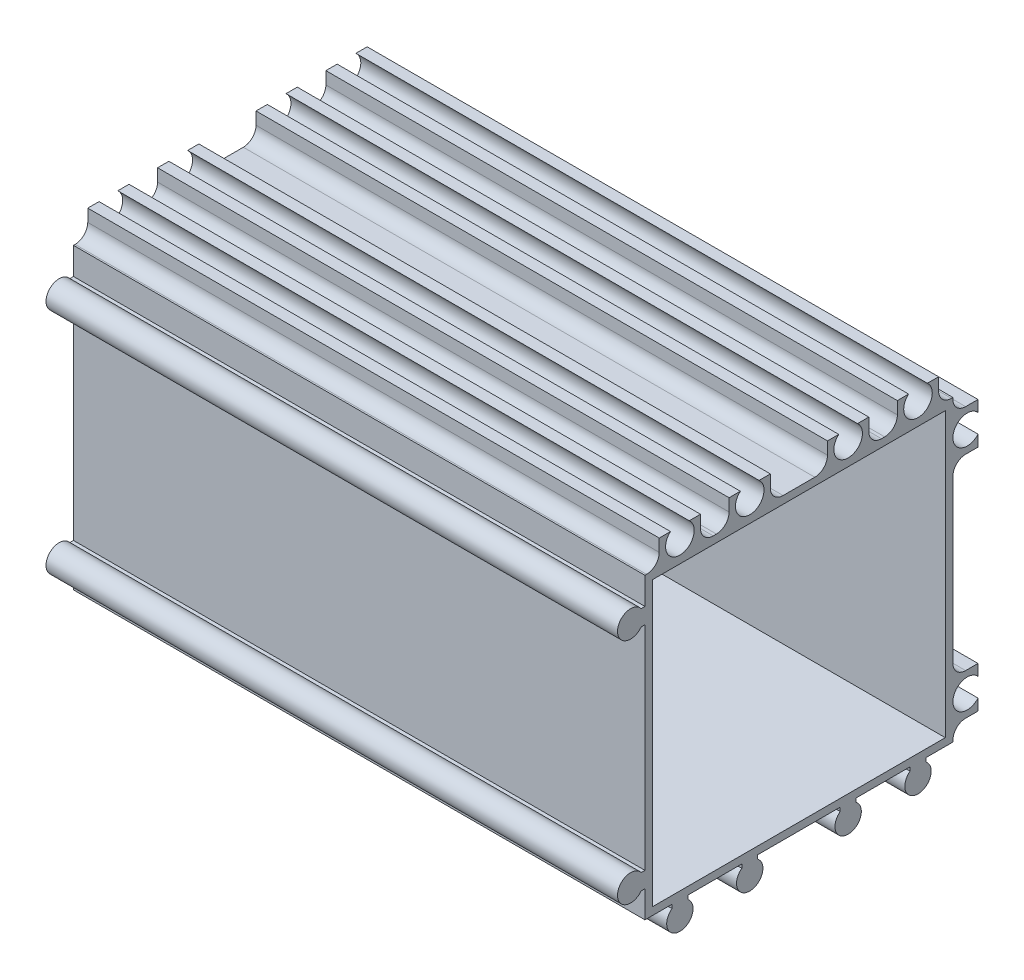
from build123d import *

# Parameters (mm, degrees)
EXTRUDE_1_DEPTH             = 90
SKETCH_2_W                  = 90
SKETCH_2_H                  = 42.75
EXTRUDE_2_DEPTH             = 8.2
SKETCH_3_W                  = 90
SKETCH_3_H                  = 52.45
EXTRUDE_3_DEPTH             = 8.2
SKETCH_4_W                  = 3.95
SKETCH_4_H                  = 2.25
CUT_EXTRUDE_1_DEPTH         = 91
SKETCH_5_W                  = 3.95
SKETCH_5_H                  = 29.5
CUT_EXTRUDE_2_DEPTH         = 91
SKETCH_6_W                  = 3.95
SKETCH_6_H                  = 6.2
CUT_EXTRUDE_3_DEPTH         = 91
SKETCH_7_W                  = 2.25
SKETCH_7_H                  = 3.95
CUT_EXTRUDE_4_DEPTH         = 91
SKETCH_8_W                  = 4.5
SKETCH_8_H                  = 3.95
CUT_EXTRUDE_5_DEPTH         = 91
SKETCH_9_W                  = 9
SKETCH_9_H                  = 3.95
CUT_EXTRUDE_6_DEPTH         = 91
SKETCH_10_W                 = 4.5
SKETCH_10_H                 = 3.95
CUT_EXTRUDE_7_DEPTH         = 91
SKETCH_11_W                 = 2.25
SKETCH_11_H                 = 3.95
CUT_EXTRUDE_8_DEPTH         = 91
SKETCH_12_W                 = 46.1
SKETCH_12_H                 = 44.6
CUT_EXTRUDE_9_DEPTH         = 86.2
HOLE_WIZARD_2_5_2_5_1_D     = 2.5
HOLE_WIZARD_2_5_2_5_1_DEPTH = 90
HOLE_WIZARD_4_5_4_5_1_D     = 4.5
HOLE_WIZARD_4_5_4_5_1_DEPTH = 90
SKETCH_19_R                 = 1.67252853
SKETCH_19_R_2               = 1.459159852
SKETCH_19_R_3               = 1.459908976
SKETCH_19_R_4               = 1.592821911
SKETCH_19_R_5               = 1.532216665
SKETCH_19_R_6               = 1.596138091
EXTRUDE_4_DEPTH             = 90
FILLET_1_R                  = 2
FILLET_2_R                  = 2
FILLET_3_R                  = 2
FILLET_4_R                  = 2
FILLET_5_R                  = 2
FILLET_6_R                  = 2
FILLET_7_R                  = 2
FILLET_8_R                  = 2
FILLET_9_R                  = 2
FILLET_10_R                 = 2
FILLET_11_R                 = 2
FILLET_12_R                 = 2


with BuildPart() as part:
    # Эскиз1 → Бобышка-Вытянуть1 (new body)
    with BuildSketch(Plane(origin=(90, 0, 0), x_dir=(0, 0, -1), z_dir=(1, 0, 0))):
        with BuildLine():
            Line((6.75, 160.906238208), (6.75, 204.25))
            Line((6.75, 204.25), (-38.093761792, 204.25))
            ThreePointArc((-38.093761792, 204.25), (-41.825, 203), (-38.093761792, 201.75))
            Line((-38.093761792, 201.75), (-37.5, 201.75))
            Line((-37.5, 201.75), (-37.5, 168.25))
            Line((-37.5, 168.25), (-38.093761792, 168.25))
            ThreePointArc((-38.093761792, 168.25), (-41.825, 167), (-38.093761792, 165.75))
            Line((-38.093761792, 165.75), (-37.5, 165.75))
            Line((-37.5, 165.75), (-37.5, 161.5))
            Line((-37.5, 161.5), (-33.25, 161.5))
            Line((-33.25, 161.5), (-33.25, 160.906238208))
            ThreePointArc((-33.25, 160.906238208), (-32, 157.175), (-30.75, 160.906238208))
            Line((-30.75, 160.906238208), (-30.75, 161.5))
            Line((-30.75, 161.5), (-22.25, 161.5))
            Line((-22.25, 161.5), (-22.25, 160.906238208))
            ThreePointArc((-22.25, 160.906238208), (-21, 157.175), (-19.75, 160.906238208))
            Line((-19.75, 160.906238208), (-19.75, 161.5))
            Line((-19.75, 161.5), (-6.75, 161.5))
            Line((-6.75, 161.5), (-6.75, 160.906238208))
            ThreePointArc((-6.75, 160.906238208), (-5.5, 157.175), (-4.25, 160.906238208))
            Line((-4.25, 160.906238208), (-4.25, 161.5))
            Line((-4.25, 161.5), (4.25, 161.5))
            Line((4.25, 161.5), (4.25, 160.906238208))
            ThreePointArc((4.25, 160.906238208), (5.5, 157.175), (6.75, 160.906238208))
        make_face()
    extrude(amount=-EXTRUDE_1_DEPTH)

    # Эскиз2 → Бобышка-Вытянуть2 (add)
    with BuildSketch(Plane(origin=(0, 0, -6.75), x_dir=(-1, 0, 0), z_dir=(0, 0, -1))):
        with Locations((-45, 182.875)):
            Rectangle(SKETCH_2_W, SKETCH_2_H)
    extrude(amount=EXTRUDE_2_DEPTH)

    # Эскиз3 → Бобышка-Вытянуть3 (add)
    with BuildSketch(Plane(origin=(0, 204.25, 0), x_dir=(-1, 0, 0), z_dir=(0, 1, 0))):
        with Locations((-45, 11.275)):
            Rectangle(SKETCH_3_W, SKETCH_3_H)
    extrude(amount=EXTRUDE_3_DEPTH)

    # Эскиз4 → Вырез-Вытянуть1 (cut, through all)
    with BuildSketch(Plane.ZY):
        with Locations((-12.975, 162.625)):
            Rectangle(SKETCH_4_W, SKETCH_4_H)
    extrude(amount=-CUT_EXTRUDE_1_DEPTH, mode=Mode.SUBTRACT)

    # Эскиз5 → Вырез-Вытянуть2 (cut, through all)
    with BuildSketch(Plane.ZY):
        with Locations((-12.975, 185)):
            Rectangle(SKETCH_5_W, SKETCH_5_H)
    extrude(amount=-CUT_EXTRUDE_2_DEPTH, mode=Mode.SUBTRACT)

    # Эскиз6 → Вырез-Вытянуть3 (cut, through all)
    with BuildSketch(Plane.ZY):
        with Locations((-12.975, 209.35)):
            Rectangle(SKETCH_6_W, SKETCH_6_H)
    extrude(amount=-CUT_EXTRUDE_3_DEPTH, mode=Mode.SUBTRACT)

    # Эскиз7 → Вырез-Вытянуть4 (cut, through all)
    with BuildSketch(Plane.ZY):
        with Locations((-9.875, 210.475)):
            Rectangle(SKETCH_7_W, SKETCH_7_H)
    extrude(amount=-CUT_EXTRUDE_4_DEPTH, mode=Mode.SUBTRACT)

    # Эскиз8 → Вырез-Вытянуть5 (cut, through all)
    with BuildSketch(Plane.ZY):
        with Locations((0, 210.475)):
            Rectangle(SKETCH_8_W, SKETCH_8_H)
    extrude(amount=-CUT_EXTRUDE_5_DEPTH, mode=Mode.SUBTRACT)

    # Эскиз9 → Вырез-Вытянуть6 (cut, through all)
    with BuildSketch(Plane.ZY):
        with Locations((13.25, 210.475)):
            Rectangle(SKETCH_9_W, SKETCH_9_H)
    extrude(amount=-CUT_EXTRUDE_6_DEPTH, mode=Mode.SUBTRACT)

    # Эскиз10 → Вырез-Вытянуть7 (cut, through all)
    with BuildSketch(Plane.ZY):
        with Locations((26.5, 210.475)):
            Rectangle(SKETCH_10_W, SKETCH_10_H)
    extrude(amount=-CUT_EXTRUDE_7_DEPTH, mode=Mode.SUBTRACT)

    # Эскиз11 → Вырез-Вытянуть8 (cut, through all)
    with BuildSketch(Plane.ZY):
        with Locations((36.375, 210.475)):
            Rectangle(SKETCH_11_W, SKETCH_11_H)
    extrude(amount=-CUT_EXTRUDE_8_DEPTH, mode=Mode.SUBTRACT)

    # Эскиз12 → Вырез-Вытянуть9 (cut)
    with BuildSketch(Plane(origin=(90, 0, 0), x_dir=(0, 0, -1), z_dir=(1, 0, 0))):
        with Locations((-13.25, 185)):
            Rectangle(SKETCH_12_W, SKETCH_12_H)
    extrude(amount=-CUT_EXTRUDE_9_DEPTH, mode=Mode.SUBTRACT)

    # Диаметр отверстия Ø2.5 (2.5)1
    with Locations(Plane(origin=(90, 0, 0), x_dir=(0, 0, -1), z_dir=(1, 0, 0))):
        with Locations((5.5, 159.25), (-21, 159.25), (-5.5, 159.25), (-32, 159.25), (-39.75, 167), (-39.75, 203)):
            Hole(HOLE_WIZARD_2_5_2_5_1_D / 2, depth=HOLE_WIZARD_2_5_2_5_1_DEPTH)

    # Диаметр отверстия Ø4.5 (4.5)1
    with Locations(Plane.ZY):
        with Locations((-13.25, 167), (-13.25, 203), (-5.5, 210.75), (5.5, 210.75), (21, 210.75), (32, 210.75)):
            Hole(HOLE_WIZARD_4_5_4_5_1_D / 2, depth=HOLE_WIZARD_4_5_4_5_1_DEPTH)

    # Эскиз19 → Бобышка-Вытянуть4 (add)
    with BuildSketch(Plane(origin=(90, 0, 0), x_dir=(0, 0, -1), z_dir=(1, 0, 0))):
        with Locations((-39.75, 203)):
            Circle(SKETCH_19_R)
        with Locations((-39.75, 167)):
            Circle(SKETCH_19_R_2)
        with Locations((-32, 159.25)):
            Circle(SKETCH_19_R_3)
        with Locations((-21, 159.25)):
            Circle(SKETCH_19_R_4)
        with Locations((-5.5, 159.25)):
            Circle(SKETCH_19_R_5)
        with Locations((5.5, 159.25)):
            Circle(SKETCH_19_R_6)
    extrude(amount=-EXTRUDE_4_DEPTH)

    # Скругление1
    fillet_1_edges = [part.edges().sort_by_distance(p)[0] for p in [
        (45, 208.5, -8.75),
    ]]
    fillet(fillet_1_edges, radius=FILLET_1_R)

    # Скругление2
    fillet_2_edges = [part.edges().sort_by_distance(p)[0] for p in [
        (45, 163.75, -11),
    ]]
    fillet(fillet_2_edges, radius=FILLET_2_R)

    # Скругление3
    fillet_3_edges = [part.edges().sort_by_distance(p)[0] for p in [
        (45, 170.25, -11),
    ]]
    fillet(fillet_3_edges, radius=FILLET_3_R)

    # Скругление4
    fillet_4_edges = [part.edges().sort_by_distance(p)[0] for p in [
        (45, 199.75, -11),
    ]]
    fillet(fillet_4_edges, radius=FILLET_4_R)

    # Скругление5
    fillet_5_edges = [part.edges().sort_by_distance(p)[0] for p in [
        (45, 206.25, -11),
    ]]
    fillet(fillet_5_edges, radius=FILLET_5_R)

    # Скругление6
    fillet_6_edges = [part.edges().sort_by_distance(p)[0] for p in [
        (45, 208.5, -2.25),
    ]]
    fillet(fillet_6_edges, radius=FILLET_6_R)

    # Скругление7
    fillet_7_edges = [part.edges().sort_by_distance(p)[0] for p in [
        (45, 208.5, 2.25),
    ]]
    fillet(fillet_7_edges, radius=FILLET_7_R)

    # Скругление8
    fillet_8_edges = [part.edges().sort_by_distance(p)[0] for p in [
        (45, 208.5, 8.75),
    ]]
    fillet(fillet_8_edges, radius=FILLET_8_R)

    # Скругление9
    fillet_9_edges = [part.edges().sort_by_distance(p)[0] for p in [
        (45, 208.5, 17.75),
    ]]
    fillet(fillet_9_edges, radius=FILLET_9_R)

    # Скругление10
    fillet_10_edges = [part.edges().sort_by_distance(p)[0] for p in [
        (45, 208.5, 24.25),
    ]]
    fillet(fillet_10_edges, radius=FILLET_10_R)

    # Скругление11
    fillet_11_edges = [part.edges().sort_by_distance(p)[0] for p in [
        (45, 208.5, 28.75),
    ]]
    fillet(fillet_11_edges, radius=FILLET_11_R)

    # Скругление12
    fillet_12_edges = [part.edges().sort_by_distance(p)[0] for p in [
        (45, 208.5, 35.25),
    ]]
    fillet(fillet_12_edges, radius=FILLET_12_R)


solid = part.part
